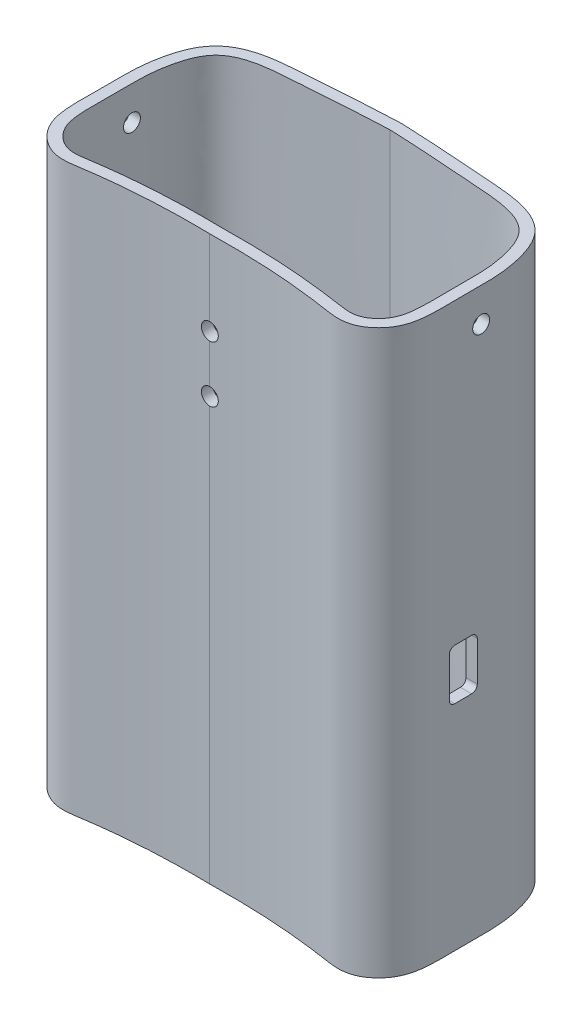
from build123d import *

# Parameters (mm, degrees)
Y_KSEKLIK_EKSTR_ZYON1_DEPTH = 100
IZIM3_R                     = 1.5
KES_EKSTR_ZYON1_DEPTH       = 10
Y_KSEKLIK_EKSTR_ZYON2_DEPTH = 4
KES_EKSTR_ZYON2_DEPTH       = 44
KES_EKSTR_ZYON3_DEPTH       = 40
KES_EKSTR_ZYON3_DEPTH_BACK  = 40
IZIM7_R                     = 1.5


with BuildPart() as part:
    # Çizim1 → Yükseklik-Ekstrüzyon1 (new body)
    with BuildSketch(Plane(origin=(0, 0, 0), x_dir=(1, 0, 0), z_dir=(0, 1, 0))):
        with BuildLine():
            add(Edge.make_bspline(
                [(0, 19.93026058), (-0.456912568, 19.913044156), (-1.378839943, 19.876102375), (-3.156788416, 19.794351658), (-5.316920069, 19.678016457), (-7.841775812, 19.519464651), (-11.189989105, 19.289535487), (-14.591856328, 19.030001897), (-18.287199098, 18.784185441), (-21.261903526, 18.486143303), (-24.224686789, 17.856341815), (-26.580303347, 16.823221448), (-28.255147115, 15.518782085), (-29.688879781, 13.830583224), (-30.777655499, 11.429600247), (-31.51434839, 8.588281022), (-31.923221921, 5.825022746), (-32.0440681, 3.056583967), (-31.987890956, 0.428578042), (-32.01708483, -2.068301489), (-32.051981724, -4.710614271), (-32.003565709, -7.406147252), (-31.648596651, -10.011539852), (-30.627497359, -12.156132439), (-29.506723331, -13.557042968), (-28.106496306, -14.69864579), (-26.704959708, -15.36667834), (-25.45815578, -15.635885952), (-24.289493621, -15.718491881), (-22.955316386, -15.603236807), (-21.618498846, -15.384071712), (-20.348009107, -15.200505648), (-19.074667671, -15.027357671), (-17.394234251, -14.818668954), (-15.310241024, -14.594364683), (-12.822903196, -14.381928941), (-9.502603912, -14.169892052), (-6.138514535, -14.059211791), (-2.68485003, -14.038099162), (-0.889123923, -14.056381118), (0, -14.071445744)],
                knots=[-0.000855941, -0.000855941, -0.000855941, -0.000855941, 0.014788494, 0.030432928, 0.061721797, 0.093010666, 0.124299534, 0.186877272, 0.218166141, 0.249455009, 0.280743878, 0.312032747, 0.327677181, 0.343321616, 0.374610484, 0.405899353, 0.437188222, 0.46847709, 0.499765959, 0.531054828, 0.562343697, 0.593632565, 0.624921434, 0.640565869, 0.656210303, 0.671854737, 0.687499172, 0.695321389, 0.703143606, 0.71878804, 0.734432475, 0.750076909, 0.765721343, 0.781365778, 0.812654647, 0.843943515, 0.875232384, 0.937810121, 0.96909899, 1.000387859, 1.000387859, 1.000387859, 1.000387859], degree=3))
            add(Edge.make_bspline(
                [(0, -14.071445744), (0.889123923, -14.056381118), (2.68485003, -14.038099162), (6.138514535, -14.059211791), (9.502603912, -14.169892052), (12.822903196, -14.381928941), (15.310241024, -14.594364683), (17.394234251, -14.818668954), (19.074667671, -15.027357671), (20.348009107, -15.200505648), (21.618498846, -15.384071712), (22.955316386, -15.603236807), (24.289493621, -15.718491881), (25.45815578, -15.635885952), (26.704959708, -15.36667834), (28.106496306, -14.69864579), (29.506723331, -13.557042968), (30.627497359, -12.156132439), (31.648596651, -10.011539852), (32.003565709, -7.406147252), (32.051981724, -4.710614271), (32.01708483, -2.068301489), (31.987890956, 0.428578042), (32.0440681, 3.056583967), (31.923221921, 5.825022746), (31.51434839, 8.588281022), (30.777655499, 11.429600247), (29.688879781, 13.830583224), (28.255147115, 15.518782085), (26.580303347, 16.823221448), (24.224686789, 17.856341815), (21.261903526, 18.486143303), (18.287199098, 18.784185441), (14.591856328, 19.030001897), (11.189989105, 19.289535487), (7.841775812, 19.519464651), (5.316920069, 19.678016457), (3.156788416, 19.794351658), (1.378839943, 19.876102375), (0.456912568, 19.913044156), (0, 19.93026058)],
                knots=[-0.000855941, -0.000855941, -0.000855941, -0.000855941, 0.030432928, 0.061721797, 0.124299534, 0.155588403, 0.186877272, 0.218166141, 0.233810575, 0.249455009, 0.265099444, 0.280743878, 0.296388312, 0.30421053, 0.312032747, 0.327677181, 0.343321616, 0.35896605, 0.374610484, 0.405899353, 0.437188222, 0.46847709, 0.499765959, 0.531054828, 0.562343697, 0.593632565, 0.624921434, 0.656210303, 0.671854737, 0.687499172, 0.71878804, 0.750076909, 0.781365778, 0.812654647, 0.875232384, 0.906521253, 0.937810121, 0.96909899, 0.984743425, 1.000387859, 1.000387859, 1.000387859, 1.000387859], degree=3))
        make_face()
        with BuildLine():
            add(Edge.make_bspline(
                [(0, 17.928841308), (-5.820212095, 17.709536244), (-13.903357487, 17.042587637), (-26.87571665, 16.196014495), (-29.550286899, 8.929250371), (-30.090469717, 4.336098712), (-29.940693307, -0.887353996), (-30.154927851, -5.701691423), (-29.637182829, -10.928766593), (-26.031174583, -14.081750554), (-15.720131404, -12.349312728), (-7.807226576, -11.938879102), (0, -12.071158692)],
                knots=[0, 0, 0, 0, 0.198459501, 0.336012796, 0.394476639, 0.459729731, 0.505376957, 0.582750838, 0.635932872, 0.690008906, 0.731880659, 1, 1, 1, 1], degree=3))
            add(Edge.make_bspline(
                [(0, 17.928841308), (5.820212095, 17.709536244), (13.903357487, 17.042587637), (26.87571665, 16.196014495), (29.550286899, 8.929250371), (30.090469717, 4.336098712), (29.940693307, -0.887353996), (30.154927851, -5.701691423), (29.637182829, -10.928766593), (26.031174583, -14.081750554), (15.720131404, -12.349312728), (7.807226576, -11.938879102), (0, -12.071158692)],
                knots=[0, 0, 0, 0, 0.198459501, 0.336012796, 0.394476639, 0.459729731, 0.505376957, 0.582750838, 0.635932872, 0.690008906, 0.731880659, 1, 1, 1, 1], degree=3))
        make_face(mode=Mode.SUBTRACT)
    extrude(amount=Y_KSEKLIK_EKSTR_ZYON1_DEPTH)

    # Çizim3 → Kes-Ekstrüzyon1 (cut)
    with BuildSketch(Plane(origin=(0, 0, 14.071445744), x_dir=(-1, 0, 0), z_dir=(0, 0, -1))):
        with Locations((0, 85)):
            Circle(IZIM3_R)
        with Locations((0, 75)):
            Circle(IZIM3_R)
    extrude(amount=KES_EKSTR_ZYON1_DEPTH, mode=Mode.SUBTRACT)

    # Çizim4 → Yükseklik-Ekstrüzyon2 (add)
    with BuildSketch(Plane.XZ):
        with BuildLine():
            add(Edge.make_bspline(
                [(0, -19.93026058), (0.456912568, -19.913044156), (1.378839943, -19.876102375), (3.156788416, -19.794351658), (5.316920069, -19.678016457), (7.841775812, -19.519464651), (11.189989105, -19.289535487), (14.591856328, -19.030001897), (18.287199098, -18.784185441), (21.261903526, -18.486143303), (24.224686789, -17.856341815), (26.580303347, -16.823221448), (28.255147115, -15.518782085), (29.688879781, -13.830583224), (30.777655499, -11.429600247), (31.51434839, -8.588281022), (31.923221921, -5.825022746), (32.0440681, -3.056583967), (31.987890956, -0.428578042), (32.01708483, 2.068301489), (32.051981724, 4.710614271), (32.003565709, 7.406147252), (31.648596651, 10.011539852), (30.627497359, 12.156132439), (29.506723331, 13.557042968), (28.106496306, 14.69864579), (26.704959708, 15.36667834), (25.45815578, 15.635885952), (24.289493621, 15.718491881), (22.955316386, 15.603236807), (21.618498846, 15.384071712), (20.348009107, 15.200505648), (19.074667671, 15.027357671), (17.394234251, 14.818668954), (15.310241024, 14.594364683), (12.822903196, 14.381928941), (9.502603912, 14.169892052), (6.138514535, 14.059211791), (2.68485003, 14.038099162), (0.889123923, 14.056381118), (0, 14.071445744)],
                knots=[-0.000855941, -0.000855941, -0.000855941, -0.000855941, 0.014788494, 0.030432928, 0.061721797, 0.093010666, 0.124299534, 0.186877272, 0.218166141, 0.249455009, 0.280743878, 0.312032747, 0.327677181, 0.343321616, 0.374610484, 0.405899353, 0.437188222, 0.46847709, 0.499765959, 0.531054828, 0.562343697, 0.593632565, 0.624921434, 0.640565869, 0.656210303, 0.671854737, 0.687499172, 0.695321389, 0.703143606, 0.71878804, 0.734432475, 0.750076909, 0.765721343, 0.781365778, 0.812654647, 0.843943515, 0.875232384, 0.937810121, 0.96909899, 1.000387859, 1.000387859, 1.000387859, 1.000387859], degree=3))
            add(Edge.make_bspline(
                [(0, 14.071445744), (-0.889123923, 14.056381118), (-2.68485003, 14.038099162), (-6.138514535, 14.059211791), (-9.502603912, 14.169892052), (-12.822903196, 14.381928941), (-15.310241024, 14.594364683), (-17.394234251, 14.818668954), (-19.074667671, 15.027357671), (-20.348009107, 15.200505648), (-21.618498846, 15.384071712), (-22.955316386, 15.603236807), (-24.289493621, 15.718491881), (-25.45815578, 15.635885952), (-26.704959708, 15.36667834), (-28.106496306, 14.69864579), (-29.506723331, 13.557042968), (-30.627497359, 12.156132439), (-31.648596651, 10.011539852), (-32.003565709, 7.406147252), (-32.051981724, 4.710614271), (-32.01708483, 2.068301489), (-31.987890956, -0.428578042), (-32.0440681, -3.056583967), (-31.923221921, -5.825022746), (-31.51434839, -8.588281022), (-30.777655499, -11.429600247), (-29.688879781, -13.830583224), (-28.255147115, -15.518782085), (-26.580303347, -16.823221448), (-24.224686789, -17.856341815), (-21.261903526, -18.486143303), (-18.287199098, -18.784185441), (-14.591856328, -19.030001897), (-11.189989105, -19.289535487), (-7.841775812, -19.519464651), (-5.316920069, -19.678016457), (-3.156788416, -19.794351658), (-1.378839943, -19.876102375), (-0.456912568, -19.913044156), (0, -19.93026058)],
                knots=[-0.000855941, -0.000855941, -0.000855941, -0.000855941, 0.030432928, 0.061721797, 0.124299534, 0.155588403, 0.186877272, 0.218166141, 0.233810575, 0.249455009, 0.265099444, 0.280743878, 0.296388312, 0.30421053, 0.312032747, 0.327677181, 0.343321616, 0.35896605, 0.374610484, 0.405899353, 0.437188222, 0.46847709, 0.499765959, 0.531054828, 0.562343697, 0.593632565, 0.624921434, 0.656210303, 0.671854737, 0.687499172, 0.71878804, 0.750076909, 0.781365778, 0.812654647, 0.875232384, 0.906521253, 0.937810121, 0.96909899, 0.984743425, 1.000387859, 1.000387859, 1.000387859, 1.000387859], degree=3))
        make_face()
    extrude(amount=-Y_KSEKLIK_EKSTR_ZYON2_DEPTH)

    # Çizim6 → Kes-Ekstrüzyon2 (cut)
    with BuildSketch(Plane(origin=(0, 0, 0), x_dir=(0, 0, -1), z_dir=(-1, 0, 0))):
        with BuildLine():
            Line((-2.571445744, -47), (0.428554256, -47))
            ThreePointArc((0.428554256, -47), (1.135661037, -46.707106781), (1.428554256, -46))
            Line((1.428554256, -46), (1.428554256, -39))
            ThreePointArc((1.428554256, -39), (1.135661037, -38.292893219), (0.428554256, -38))
            Line((0.428554256, -38), (-2.571445744, -38))
            ThreePointArc((-2.571445744, -38), (-3.278552525, -38.292893219), (-3.571445744, -39))
            Line((-3.571445744, -39), (-3.571445744, -46))
            ThreePointArc((-3.571445744, -46), (-3.278552525, -46.707106781), (-2.571445744, -47))
        make_face()
    extrude(amount=-KES_EKSTR_ZYON2_DEPTH, mode=Mode.SUBTRACT)

    # Çizim7 → Kes-Ekstrüzyon3 (cut, two sides: drawn at the far end of the back side and taken through both)
    with BuildSketch(Plane(origin=(0, 0, 0), x_dir=(0, 0, -1), z_dir=(-1, 0, 0)).offset(-KES_EKSTR_ZYON3_DEPTH_BACK)):
        with Locations((2.122513832, -94)):
            Circle(IZIM7_R)
    extrude(amount=KES_EKSTR_ZYON3_DEPTH + KES_EKSTR_ZYON3_DEPTH_BACK, mode=Mode.SUBTRACT)


solid = part.part
